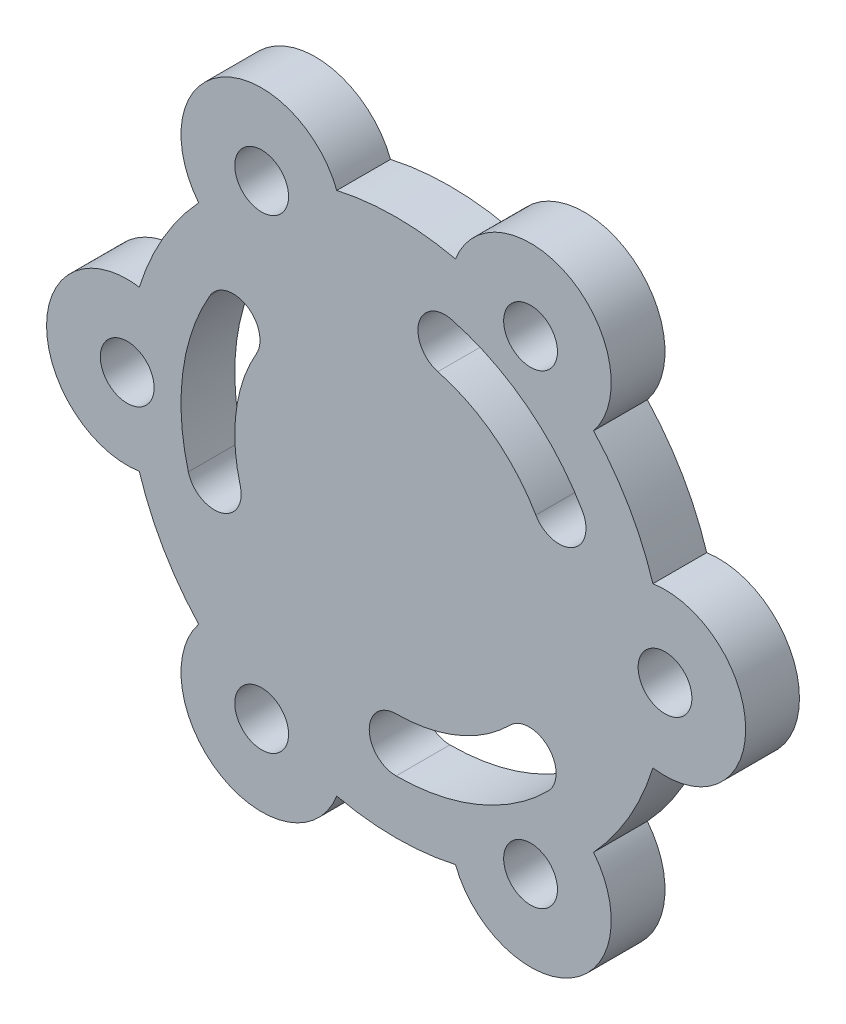
from build123d import *

# Parameters (mm, degrees)
SKETCH1_R           = 5
BOSS_EXTRUDE1_DEPTH = 10


with BuildPart() as part:
    # Sketch1 → Boss-Extrude1 (new body)
    with BuildSketch(Plane.XY):
        with BuildLine():
            ThreePointArc((-47.75, 14.83028995), (-65, 0), (-47.75, -14.83028995))
            ThreePointArc((-47.75, -14.83028995), (-43.301270189, -25), (-36.718407842, -33.937568056))
            ThreePointArc((-36.718407842, -33.937568056), (-32.5, -56.291651246), (-11.031592158, -48.767858006))
            ThreePointArc((-11.031592158, -48.767858006), (0, -50), (11.031592158, -48.767858006))
            ThreePointArc((11.031592158, -48.767858006), (32.5, -56.291651246), (36.718407842, -33.937568056))
            ThreePointArc((36.718407842, -33.937568056), (43.301270189, -25), (47.75, -14.83028995))
            ThreePointArc((47.75, -14.83028995), (65, 0), (47.75, 14.83028995))
            ThreePointArc((47.75, 14.83028995), (43.301270189, 25), (36.718407842, 33.937568056))
            ThreePointArc((36.718407842, 33.937568056), (32.5, 56.291651246), (11.031592158, 48.767858006))
            ThreePointArc((11.031592158, 48.767858006), (0, 50), (-11.031592158, 48.767858006))
            ThreePointArc((-11.031592158, 48.767858006), (-32.5, 56.291651246), (-36.718407842, 33.937568056))
            ThreePointArc((-36.718407842, 33.937568056), (-43.301270189, 25), (-47.75, 14.83028995))
        make_face()
        with Locations((-50, 0)):
            Circle(SKETCH1_R, mode=Mode.SUBTRACT)
        with Locations((-25, 43.301270189)):
            Circle(SKETCH1_R, mode=Mode.SUBTRACT)
        with Locations((25, 43.301270189)):
            Circle(SKETCH1_R, mode=Mode.SUBTRACT)
        with Locations((50, 0)):
            Circle(SKETCH1_R, mode=Mode.SUBTRACT)
        with Locations((25, -43.301270189)):
            Circle(SKETCH1_R, mode=Mode.SUBTRACT)
        with Locations((-25, -43.301270189)):
            Circle(SKETCH1_R, mode=Mode.SUBTRACT)
        with BuildLine():
            ThreePointArc((34.641016151, 20), (24.35045716, 31.734133612), (10.352761804, 38.637033052))
            ThreePointArc((10.352761804, 38.637033052), (4.229037447, 35.101499146), (7.764571353, 28.977774789))
            ThreePointArc((7.764571353, 28.977774789), (18.26284287, 23.800600209), (25.980762114, 15))
            ThreePointArc((25.980762114, 15), (32.810889132, 13.169872981), (34.641016151, 20))
        make_face(mode=Mode.SUBTRACT)
        with BuildLine():
            ThreePointArc((0, -40), (15.307337295, -36.9551813), (28.284271247, -28.284271247))
            ThreePointArc((28.284271247, -28.284271247), (28.284271247, -21.213203436), (21.213203436, -21.213203436))
            ThreePointArc((21.213203436, -21.213203436), (11.480502971, -27.716385975), (0, -30))
            ThreePointArc((0, -30), (-5, -35), (0, -40))
        make_face(mode=Mode.SUBTRACT)
        with BuildLine():
            ThreePointArc((-34.641016151, 20), (-39.657794455, 5.221047689), (-38.637033052, -10.352761804))
            ThreePointArc((-38.637033052, -10.352761804), (-32.513308695, -13.88829571), (-28.977774789, -7.764571353))
            ThreePointArc((-28.977774789, -7.764571353), (-29.743345841, 3.915785767), (-25.980762114, 15))
            ThreePointArc((-25.980762114, 15), (-27.810889132, 21.830127019), (-34.641016151, 20))
        make_face(mode=Mode.SUBTRACT)
    extrude(amount=BOSS_EXTRUDE1_DEPTH)


solid = part.part
